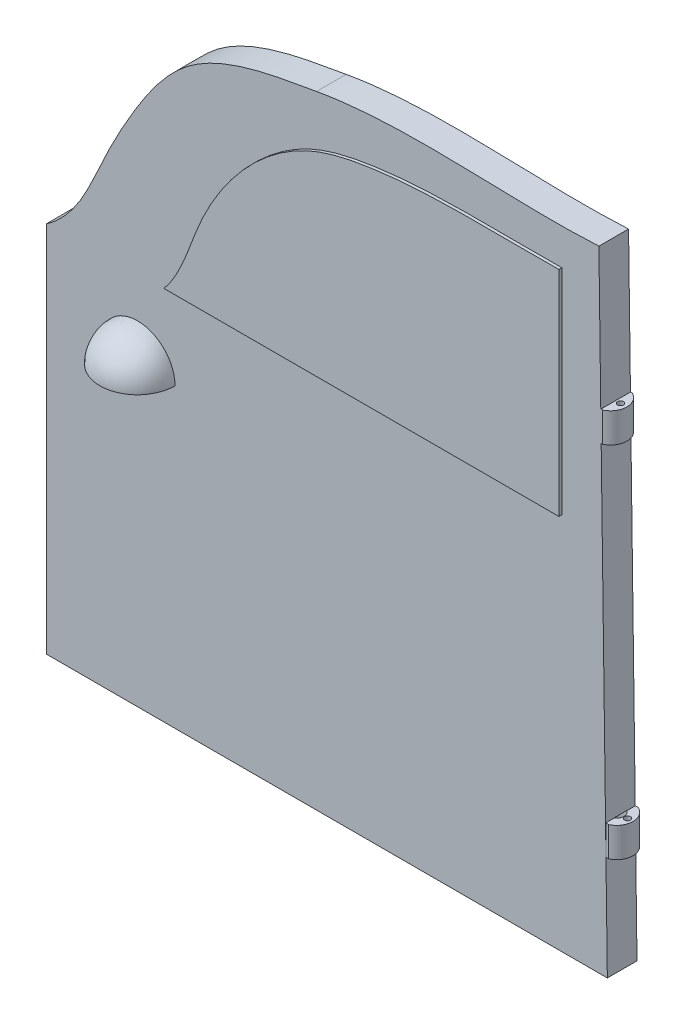
from build123d import *

# Parameters (mm, degrees)
BOSS_EXTRUDE1_DEPTH          = 10
BOSS_EXTRUDE2_DEPTH          = 1
BOSS_EXTRUDE2_DEPTH_BACK     = 11
REVOLVE1_ANGLE               = 90
CUT_REVOLVE1_ANGLE           = 45
CUT_REVOLVE1_OTHER_WAY_ANGLE = 90
BOSS_EXTRUDE3_DEPTH          = 5
BOSS_EXTRUDE3_DEPTH_BACK     = 5
BOSS_EXTRUDE4_DEPTH          = 5
BOSS_EXTRUDE4_DEPTH_BACK     = 5
SKETCH19_R                   = 1
CUT_EXTRUDE3_DEPTH           = 10
SKETCH24_R                   = 1
CUT_EXTRUDE4_DEPTH           = 10
SKETCH21_R                   = 2.5
CUT_EXTRUDE2_DEPTH           = 10


with BuildPart() as part:
    # Sketch1 → Boss-Extrude1 (new body)
    with BuildSketch(Plane.XY):
        with BuildLine():
            Line((186.280110435, 212.216863761), (189.127439812, 0))
            Line((189.127439812, 0), (0, 0))
            Line((0, 0), (0, 125.576698411))
            add(Edge.make_bspline(
                [(0, 125.576698411), (10.557001905, 132.837635912), (17.098165485, 150.751131911), (30.538510921, 175.76338894), (49.352217031, 203.04075133), (76.867896029, 207.296992896), (91.097956951, 209.776295723)],
                knots=[0, 0, 0, 0, 0.275246051, 0.426571591, 0.655828837, 1, 1, 1, 1], degree=3))
            add(Edge.make_bspline(
                [(91.097956951, 209.776295723), (122.565116695, 215.374757588), (154.60100966, 210.515513687), (186.280110435, 212.216863761)],
                knots=[0, 0, 0, 0, 1, 1, 1, 1], degree=3))
        make_face()
    extrude(amount=BOSS_EXTRUDE1_DEPTH)

    # Sketch3 → Boss-Extrude2 (add, two sides: drawn at the far end of the back side and taken through both)
    with BuildSketch(Plane.XY.offset(10).offset(-BOSS_EXTRUDE2_DEPTH_BACK)):
        with BuildLine():
            Line((40.691917073, 127.565231362), (173.80372619, 127.565231362))
            Line((173.80372619, 127.565231362), (173.80372619, 199.679337801))
            add(Edge.make_bspline(
                [(40.691917073, 127.565231362), (46.771290341, 134.933306827), (53.369134393, 161.704453989), (78.457507643, 191.212262771), (124.31750344, 201.038762955), (152.264868916, 199.362802741), (173.80372619, 199.679337801)],
                knots=[0, 0, 0, 0, 0.16561761, 0.500501685, 0.611599227, 1, 1, 1, 1], degree=3))
        make_face()
    extrude(amount=BOSS_EXTRUDE2_DEPTH + BOSS_EXTRUDE2_DEPTH_BACK)

    # Sketch4 → Revolve1 (revolve)
    with BuildSketch(Plane.XY.offset(10)):
        with BuildLine():
            Line((18.099024499, 100.001165305), (43.413071111, 100.001165305))
            ThreePointArc((43.413071111, 100.001165305), (30.756047805, 112.658188611), (18.099024499, 100.001165305))
        make_face()
    revolve(axis=Axis((18.099024499, 100.001165305, 10), (1, 0, 0)), revolution_arc=REVOLVE1_ANGLE)

    # Sketch7 → Cut-Revolve1 (revolve, cut)
    with BuildSketch(Plane.XZ.offset(-100.001165305)):
        with BuildLine():
            Line((19.785436848, 10), (41.915940994, 10))
            ThreePointArc((41.915940994, 10), (30.850688921, 20.07738513), (19.785436848, 10))
        make_face()
    revolve(axis=Axis((19.785436848, 100.001165305, 10), (1, 0, 0)), revolution_arc=CUT_REVOLVE1_ANGLE, mode=Mode.SUBTRACT)

    # Sketch7 → Cut-Revolve1 other way (revolve, cut)
    with BuildSketch(Plane.XZ.offset(-100.001165305)):
        with BuildLine():
            Line((19.785436848, 10), (41.915940994, 10))
            ThreePointArc((41.915940994, 10), (30.850688921, 20.07738513), (19.785436848, 10))
        make_face()
    revolve(axis=Axis((19.785436848, 100.001165305, 10), (-1, 0, 0)), revolution_arc=CUT_REVOLVE1_OTHER_WAY_ANGLE, mode=Mode.SUBTRACT)

    # Sketch17 → Boss-Extrude3 (add, two sides: drawn at the far end of the back side and taken through both)
    with BuildSketch(Plane(origin=(0, 40, 0), x_dir=(-1, 0, 0), z_dir=(0, -1, 0)).offset(-BOSS_EXTRUDE3_DEPTH_BACK)):
        with BuildLine():
            Line((-188.57501815, 0), (-189.57501815, 0))
            ThreePointArc((-189.57501815, 0), (-192.762810227, -4.99036016), (-189.57501815, -9.98072032))
            Line((-189.57501815, -9.98072032), (-188.57501815, -9.98072032))
            Line((-188.57501815, -9.98072032), (-188.57501815, 0))
        make_face()
    extrude(amount=BOSS_EXTRUDE3_DEPTH + BOSS_EXTRUDE3_DEPTH_BACK)

    # Sketch18 → Boss-Extrude4 (add, two sides: drawn at the far end of the back side and taken through both)
    with BuildSketch(Plane(origin=(0, 160, 0), x_dir=(-1, 0, 0), z_dir=(0, -1, 0)).offset(-BOSS_EXTRUDE4_DEPTH_BACK)):
        with BuildLine():
            Line((-186.972854644, -10), (-187.472854644, -10))
            ThreePointArc((-187.472854644, -10), (-190.720096746, -5), (-187.472854644, 0))
            Line((-187.472854644, 0), (-186.972854644, 0))
            Line((-186.972854644, 0), (-186.972854644, -10))
        make_face()
    extrude(amount=BOSS_EXTRUDE4_DEPTH + BOSS_EXTRUDE4_DEPTH_BACK)

    # Sketch19 → Cut-Extrude3 (cut)
    with BuildSketch(Plane.XZ.offset(-155)):
        with Locations((188.57501815, 5)):
            Circle(SKETCH19_R)
    extrude(amount=-CUT_EXTRUDE3_DEPTH, mode=Mode.SUBTRACT)

    # Sketch24 → Cut-Extrude4 (cut)
    with BuildSketch(Plane.XZ.offset(-35)):
        with Locations((190.94512502, 4.99518008)):
            Circle(SKETCH24_R)
    extrude(amount=-CUT_EXTRUDE4_DEPTH, mode=Mode.SUBTRACT)

    # Sketch21 → Cut-Extrude2 (cut)
    with BuildSketch(Plane(origin=(0, 45, 0), x_dir=(1, 0, 0), z_dir=(0, 1, 0))):
        with Locations((187.262810227, -4.99036016)):
            Circle(SKETCH21_R)
    extrude(amount=-CUT_EXTRUDE2_DEPTH, mode=Mode.SUBTRACT)


solid = part.part
